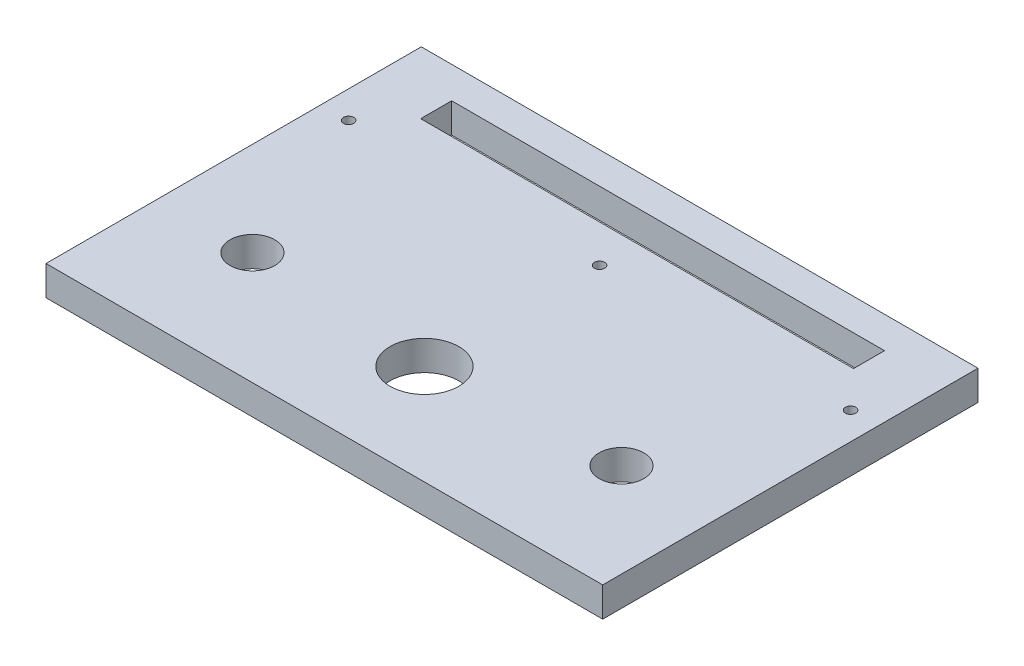
from build123d import *

# Parameters (mm, degrees)
SKETCH1_W           = 178
SKETCH1_H           = 120
SKETCH1_R           = 11
SKETCH1_R_2         = 7.15
SKETCH1_W_2         = 138.4
SKETCH1_H_2         = 9.9
BOSS_EXTRUDE1_DEPTH = 9.5
M4_TAPPED_HOLE1_D   = 3.3


with BuildPart() as part:
    # Sketch1 → Boss-Extrude1 (new body)
    with BuildSketch(Plane(origin=(0, 0, 0), x_dir=(1, 0, 0), z_dir=(0, 1, 0))):
        Rectangle(SKETCH1_W, SKETCH1_H)
        with Locations((0, -28)):
            Circle(SKETCH1_R, mode=Mode.SUBTRACT)
        with Locations((-59, -24)):
            Circle(SKETCH1_R_2, mode=Mode.SUBTRACT)
        with Locations((59, -24)):
            Circle(SKETCH1_R_2, mode=Mode.SUBTRACT)
        with Locations((0, 44.95)):
            Rectangle(SKETCH1_W_2, SKETCH1_H_2, mode=Mode.SUBTRACT)
    extrude(amount=BOSS_EXTRUDE1_DEPTH)

    # M4 Tapped Hole1 (through all)
    with Locations(Plane(origin=(0, 9.5, 0), x_dir=(1, 0, 0), z_dir=(0, 1, 0))):
        with Locations((-80.25, 28), (0, 28), (80.25, 28)):
            Hole(M4_TAPPED_HOLE1_D / 2)


solid = part.part
